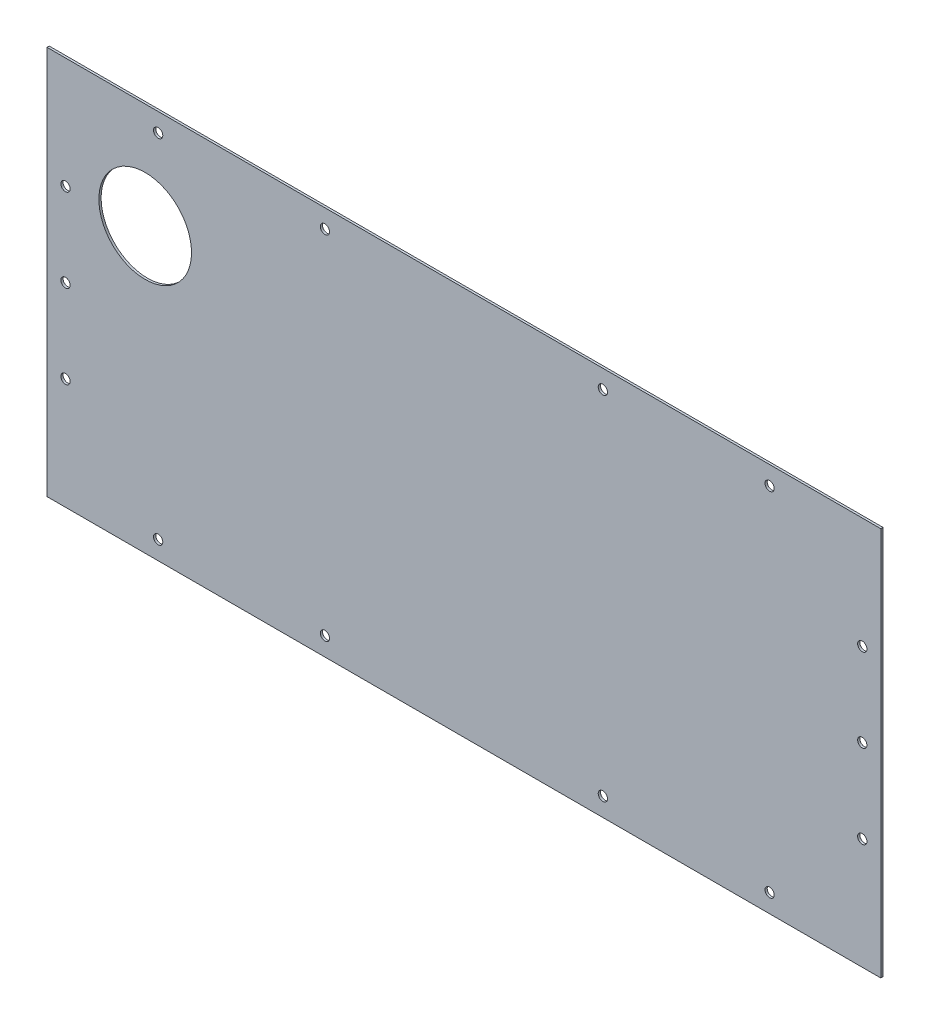
from build123d import *

# Parameters (mm, degrees)
SURFACE_EXTRUDE1_1_DEPTH = 450
THICKEN15_T2             = 1.2
SKETCH2_R                = 25
CUT_EXTRUDE1_DEPTH       = 10
SKETCH3_R                = 2.5
CUT_EXTRUDE2_DEPTH       = 10


with BuildPart() as body_1:
    # Surface-Extrude1: a surface, the sketch's curves swept straight by 450 mm
    with BuildLine(Plane(origin=(0, 0, 0), x_dir=(0, 0, -1), z_dir=(1, 0, 0)), mode=Mode.PRIVATE) as surface_extrude1_1_path:
        Line((0, 0), (0, 210))
    surface_extrude1_1 = Shell.extrude(surface_extrude1_1_path.wire(), (1 * SURFACE_EXTRUDE1_1_DEPTH, 0 * SURFACE_EXTRUDE1_1_DEPTH, 0 * SURFACE_EXTRUDE1_1_DEPTH))
    add(Solid.thicken(surface_extrude1_1, -THICKEN15_T2))

    # Sketch2 → Cut-Extrude1 (cut)
    with BuildSketch(Plane.XY):
        with Locations((53, 153)):
            Circle(SKETCH2_R)
    extrude(amount=-CUT_EXTRUDE1_DEPTH, mode=Mode.SUBTRACT)

    # Sketch3 → Cut-Extrude2 (cut)
    with BuildSketch(Plane.XY):
        with Locations((10, 60)):
            Circle(SKETCH3_R)
        with Locations((10, 105)):
            Circle(SKETCH3_R)
        with Locations((10, 150)):
            Circle(SKETCH3_R)
        with Locations(Location((440, 60, 0), (0, 0, 180))):
            Circle(SKETCH3_R)
        with Locations(Location((440, 105, 0), (0, 0, 180))):
            Circle(SKETCH3_R)
        with Locations(Location((440, 150, 0), (0, 0, 180))):
            Circle(SKETCH3_R)
        with Locations((60, 200)):
            Circle(SKETCH3_R)
        with Locations((150, 200)):
            Circle(SKETCH3_R)
        with Locations(Location((300, 200, 0), (0, 0, 180))):
            Circle(SKETCH3_R)
        with Locations(Location((390, 200, 0), (0, 0, 180))):
            Circle(SKETCH3_R)
        with Locations((390, 10)):
            Circle(SKETCH3_R)
        with Locations((300, 10)):
            Circle(SKETCH3_R)
        with Locations(Location((150, 10, 0), (0, 0, 180))):
            Circle(SKETCH3_R)
        with Locations(Location((60, 10, 0), (0, 0, 180))):
            Circle(SKETCH3_R)
    extrude(amount=-CUT_EXTRUDE2_DEPTH, mode=Mode.SUBTRACT)


solid = body_1.part
